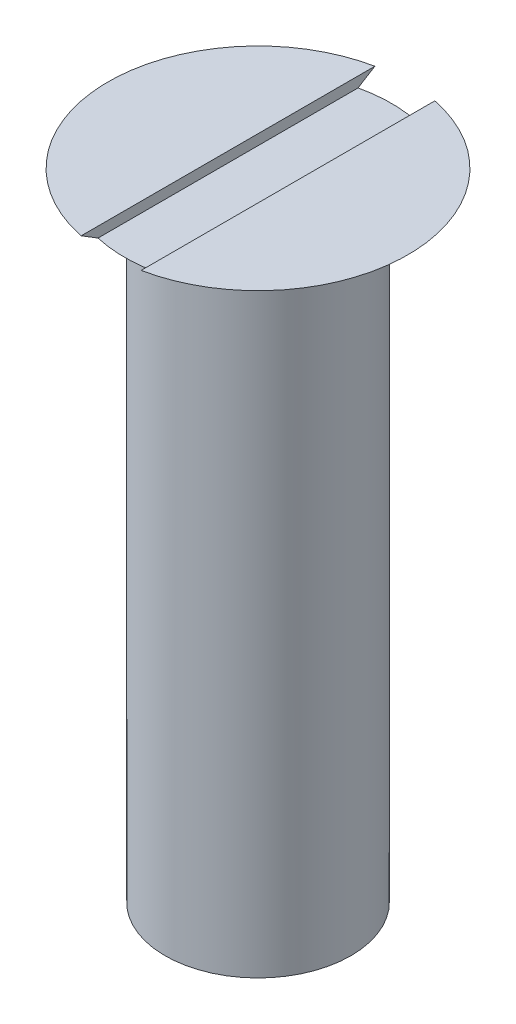
from build123d import *

# Parameters (mm, degrees)
SKETCH2_W               = 1
SKETCH2_H               = 0.346635712
CUT_EXTRUDE1_DEPTH      = 3.5
CUT_EXTRUDE1_DEPTH_BACK = 3.5


with BuildPart() as part:
    # Sketch1 → Revolve1 (revolve)
    with BuildSketch(Plane.XY):
        Polygon((0, 0), (1.55, 0), (1.55, 10), (2.5, 10.6), (0, 10.6), align=None)
    revolve(axis=Axis((0, 0, 0), (0, 1, 0)))

    # Sketch2 → Cut-Extrude1 (cut, two sides)
    with BuildSketch(Plane.XY) as cut_extrude1_sk:
        with Locations((0, 10.6)):
            Rectangle(SKETCH2_W, SKETCH2_H)
    extrude(amount=CUT_EXTRUDE1_DEPTH, mode=Mode.SUBTRACT)
    extrude(cut_extrude1_sk.sketch, amount=-CUT_EXTRUDE1_DEPTH_BACK, mode=Mode.SUBTRACT)


solid = part.part
